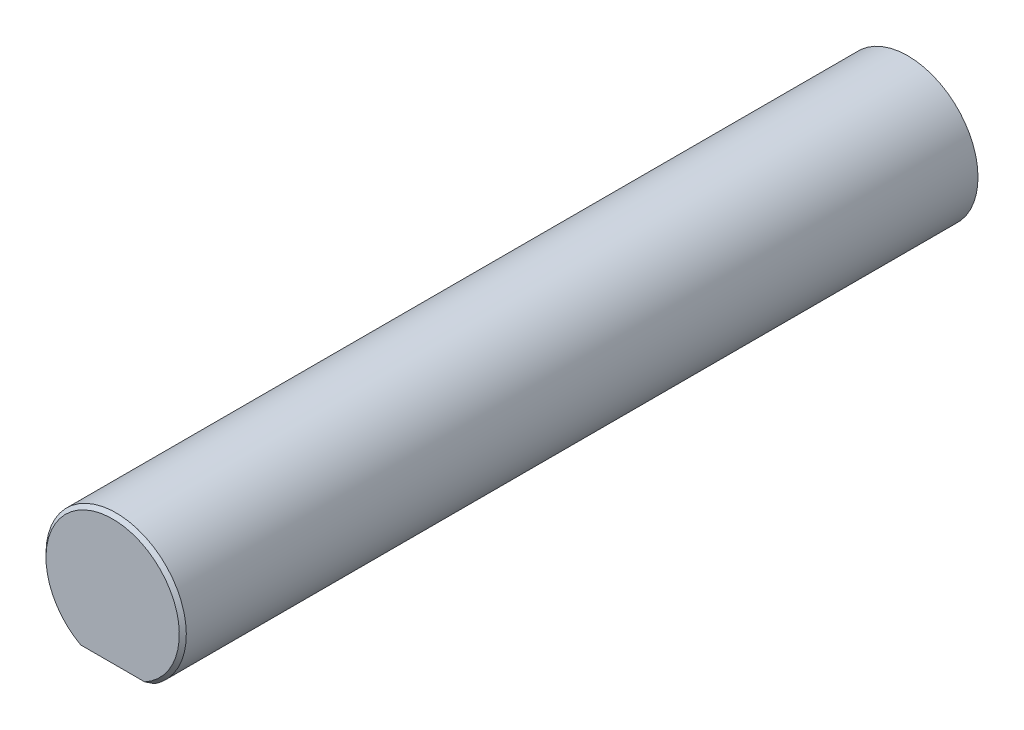
from build123d import *

# Parameters (mm, degrees)
SKETCH1_R           = 3
BOSS_EXTRUDE1_DEPTH = 22
BOSS_EXTRUDE2_DEPTH = 12
CHAMFER1_SIZE       = 0.15


with BuildPart() as part:
    # Sketch1 → Boss-Extrude1 (new body)
    with BuildSketch(Plane.XY):
        Circle(SKETCH1_R)
    extrude(amount=BOSS_EXTRUDE1_DEPTH)

    # Sketch2 → Boss-Extrude2 (add)
    with BuildSketch(Plane.XY.offset(22)):
        with BuildLine():
            ThreePointArc((1.658312395, -2.5), (0, 3), (-1.658312395, -2.5))
            Line((-1.658312395, -2.5), (1.658312395, -2.5))
        make_face()
    extrude(amount=BOSS_EXTRUDE2_DEPTH)

    # Chamfer1
    chamfer1_edges = [part.edges().sort_by_distance(p)[0] for p in [
        (0, 3, 34),
    ]]
    chamfer(chamfer1_edges, length=CHAMFER1_SIZE)


solid = part.part
